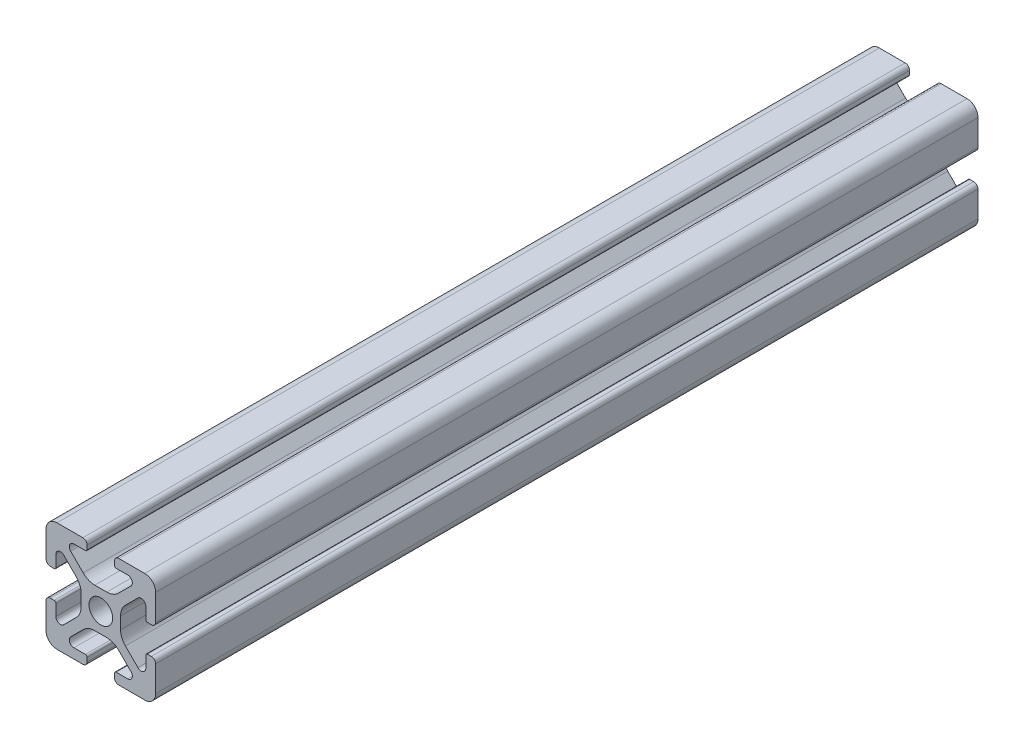
from build123d import *

# Parameters (mm, degrees)
SKETCH3_R           = 2.15
BOSS_EXTRUDE1_DEPTH = 150


with BuildPart() as part:
    # Sketch3 → Boss-Extrude1 (new body)
    with BuildSketch(Plane.XY):
        with BuildLine():
            Line((3.2874, 10), (8, 10))
            ThreePointArc((8, 10), (9.414213562, 9.414213562), (10, 8))
            Line((10, 8), (10, 3.2874))
            ThreePointArc((10, 3.2874), (9.76937588, 2.73062412), (9.2126, 2.5))
            Line((9.2126, 2.5), (8.5048, 2.5))
            ThreePointArc((8.5048, 2.5), (8.289273853, 2.589273853), (8.2, 2.8048))
            Line((8.2, 2.8048), (8.2, 4.9118))
            ThreePointArc((8.2, 4.9118), (7.682565253, 5.686195824), (6.769103096, 5.504496904))
            Line((6.769103096, 5.504496904), (4.478679656, 3.214073464))
            ThreePointArc((4.478679656, 3.214073464), (3.828361402, 2.240803418), (3.6, 1.092753121))
            Line((3.6, 1.092753121), (3.6, -1.092753121))
            ThreePointArc((3.6, -1.092753121), (3.828361402, -2.240803418), (4.478679656, -3.214073464))
            Line((4.478679656, -3.214073464), (6.769103096, -5.504496904))
            ThreePointArc((6.769103096, -5.504496904), (7.682565253, -5.686195824), (8.2, -4.9118))
            Line((8.2, -4.9118), (8.2, -2.8048))
            ThreePointArc((8.2, -2.8048), (8.289273853, -2.589273853), (8.5048, -2.5))
            Line((8.5048, -2.5), (9.2126, -2.5))
            ThreePointArc((9.2126, -2.5), (9.76937588, -2.73062412), (10, -3.2874))
            Line((10, -3.2874), (10, -8))
            ThreePointArc((10, -8), (9.414213562, -9.414213562), (8, -10))
            Line((8, -10), (3.2874, -10))
            ThreePointArc((3.2874, -10), (2.73062412, -9.76937588), (2.5, -9.2126))
            Line((2.5, -9.2126), (2.5, -8.5048))
            ThreePointArc((2.5, -8.5048), (2.589273853, -8.289273853), (2.8048, -8.2))
            Line((2.8048, -8.2), (4.9118, -8.2))
            ThreePointArc((4.9118, -8.2), (5.686195824, -7.682565253), (5.504496904, -6.769103096))
            Line((5.504496904, -6.769103096), (3.214073464, -4.478679656))
            ThreePointArc((3.214073464, -4.478679656), (2.240803418, -3.828361402), (1.092753121, -3.6))
            Line((1.092753121, -3.6), (-1.092753121, -3.6))
            ThreePointArc((-1.092753121, -3.6), (-2.240803418, -3.828361402), (-3.214073464, -4.478679656))
            Line((-3.214073464, -4.478679656), (-5.504496904, -6.769103096))
            ThreePointArc((-5.504496904, -6.769103096), (-5.686195824, -7.682565253), (-4.9118, -8.2))
            Line((-4.9118, -8.2), (-2.8048, -8.2))
            ThreePointArc((-2.8048, -8.2), (-2.589273853, -8.289273853), (-2.5, -8.5048))
            Line((-2.5, -8.5048), (-2.5, -9.2126))
            ThreePointArc((-2.5, -9.2126), (-2.73062412, -9.76937588), (-3.2874, -10))
            Line((-3.2874, -10), (-8, -10))
            ThreePointArc((-8, -10), (-9.414213562, -9.414213562), (-10, -8))
            Line((-10, -8), (-10, -3.2874))
            ThreePointArc((-10, -3.2874), (-9.76937588, -2.73062412), (-9.2126, -2.5))
            Line((-9.2126, -2.5), (-8.5048, -2.5))
            ThreePointArc((-8.5048, -2.5), (-8.289273853, -2.589273853), (-8.2, -2.8048))
            Line((-8.2, -2.8048), (-8.2, -4.9118))
            ThreePointArc((-8.2, -4.9118), (-7.682565253, -5.686195824), (-6.769103096, -5.504496904))
            Line((-6.769103096, -5.504496904), (-4.478679656, -3.214073464))
            ThreePointArc((-4.478679656, -3.214073464), (-3.828361402, -2.240803418), (-3.6, -1.092753121))
            Line((-3.6, -1.092753121), (-3.6, 1.092753121))
            ThreePointArc((-3.6, 1.092753121), (-3.828361402, 2.240803418), (-4.478679656, 3.214073464))
            Line((-4.478679656, 3.214073464), (-6.769103096, 5.504496904))
            ThreePointArc((-6.769103096, 5.504496904), (-7.682565253, 5.686195824), (-8.2, 4.9118))
            Line((-8.2, 4.9118), (-8.2, 2.8048))
            ThreePointArc((-8.2, 2.8048), (-8.289273853, 2.589273853), (-8.5048, 2.5))
            Line((-8.5048, 2.5), (-9.2126, 2.5))
            ThreePointArc((-9.2126, 2.5), (-9.76937588, 2.73062412), (-10, 3.2874))
            Line((-10, 3.2874), (-10, 8))
            ThreePointArc((-10, 8), (-9.414213562, 9.414213562), (-8, 10))
            Line((-8, 10), (-3.2874, 10))
            ThreePointArc((-3.2874, 10), (-2.73062412, 9.76937588), (-2.5, 9.2126))
            Line((-2.5, 9.2126), (-2.5, 8.5048))
            ThreePointArc((-2.5, 8.5048), (-2.589273853, 8.289273853), (-2.8048, 8.2))
            Line((-2.8048, 8.2), (-4.9118, 8.2))
            ThreePointArc((-4.9118, 8.2), (-5.686195824, 7.682565253), (-5.504496904, 6.769103096))
            Line((-5.504496904, 6.769103096), (-3.214073464, 4.478679656))
            ThreePointArc((-3.214073464, 4.478679656), (-2.240803418, 3.828361402), (-1.092753121, 3.6))
            Line((-1.092753121, 3.6), (1.092753121, 3.6))
            ThreePointArc((1.092753121, 3.6), (2.240803418, 3.828361402), (3.214073464, 4.478679656))
            Line((3.214073464, 4.478679656), (5.504496904, 6.769103096))
            ThreePointArc((5.504496904, 6.769103096), (5.686195824, 7.682565253), (4.9118, 8.2))
            Line((4.9118, 8.2), (2.8048, 8.2))
            ThreePointArc((2.8048, 8.2), (2.589273853, 8.289273853), (2.5, 8.5048))
            Line((2.5, 8.5048), (2.5, 9.2126))
            ThreePointArc((2.5, 9.2126), (2.73062412, 9.76937588), (3.2874, 10))
        make_face()
        Circle(SKETCH3_R, mode=Mode.SUBTRACT)
    extrude(amount=BOSS_EXTRUDE1_DEPTH)


solid = part.part
